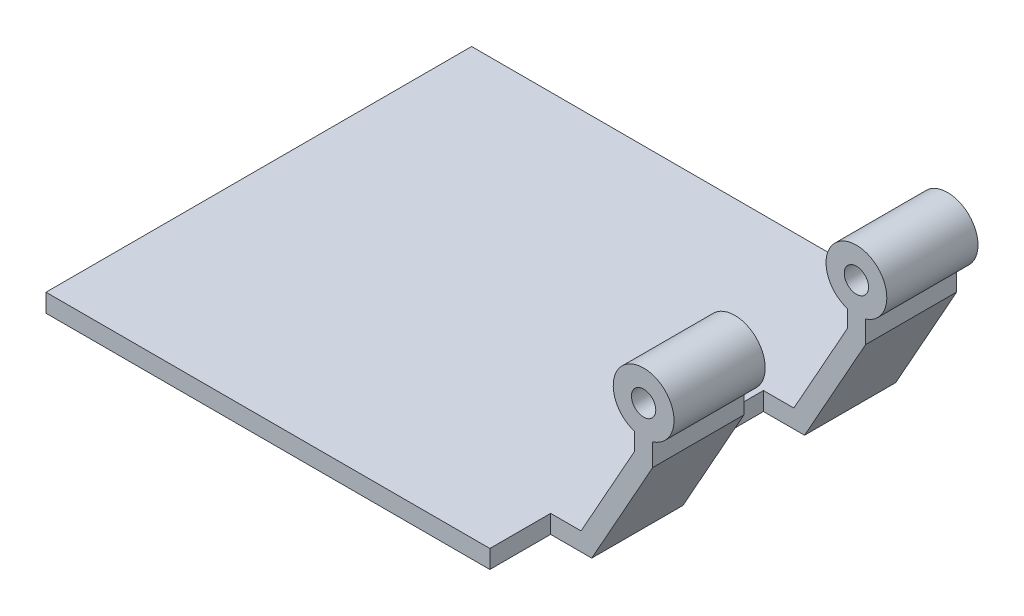
from build123d import *

# Parameters (mm, degrees)
SKETCH1_R               = 5
BOSS_EXTRUDE1_DEPTH     = 50
SKETCH2_R               = 2
CUT_EXTRUDE1_DEPTH      = 51
SKETCH7_W               = 20
SKETCH7_H               = 39.987182744
CUT_EXTRUDE3_DEPTH      = 10
CUT_EXTRUDE3_DEPTH_BACK = 10
BOSS_EXTRUDE2_REACH     = 52
CUT_EXTRUDE4_REACH      = 97.292
SKETCH9_W               = 20
SKETCH9_H               = 10.896319728
CUT_EXTRUDE6_REACH      = 52
SKETCH11_W              = 5
SKETCH11_H              = 3
SKETCH12_W              = 73
SKETCH12_H              = 70
BOSS_EXTRUDE3_DEPTH     = 3
SKETCH13_W              = 6.758772051
SKETCH13_H              = 20
CUT_EXTRUDE7_DEPTH      = 4


with BuildPart() as part:
    # Sketch1 → Boss-Extrude1 (new body)
    with BuildSketch(Plane.XY):
        with Locations((90.291740814, 26.352640412)):
            Circle(SKETCH1_R)
        Polygon((0, 3), (0, 0), (81.758772051, 0), (91.791740814, 17.924366601), (91.791740814, 23.706854983), (88.791740814, 23.706854983), (88.791740814, 18.706854983), (80, 3), align=None)
    extrude(amount=BOSS_EXTRUDE1_DEPTH)

    # Sketch2 → Cut-Extrude1 (cut, through all)
    with BuildSketch(Plane.XY):
        with Locations((90.291740814, 26.352640412)):
            Circle(SKETCH2_R)
    extrude(amount=CUT_EXTRUDE1_DEPTH, mode=Mode.SUBTRACT)

    # Sketch7 → Cut-Extrude3 (cut, two sides)
    with BuildSketch(Plane(origin=(62.254079791, -34.846042362, 0), x_dir=(0, 0, -1), z_dir=(0.872603055, -0.488430045, 0))) as cut_extrude3_sk:
        with Locations((-25, 59.927032101)):
            Rectangle(SKETCH7_W, SKETCH7_H)
    extrude(amount=CUT_EXTRUDE3_DEPTH, mode=Mode.SUBTRACT)
    extrude(cut_extrude3_sk.sketch, amount=-CUT_EXTRUDE3_DEPTH_BACK, mode=Mode.SUBTRACT)

    # Sketch8 → Boss-Extrude2 (add, up to next)
    with BuildSketch(Plane.XY, mode=Mode.PRIVATE) as boss_extrude2_sk1:
        Polygon((66.951015515, 3), (66.951015515, 0), (81.758772051, 0), (79.25400484, 1.667244856), (80, 3), align=None)
    boss_extrude2_tool1 = extrude(boss_extrude2_sk1.sketch, amount=BOSS_EXTRUDE2_REACH, mode=Mode.PRIVATE) - part.part
    add(boss_extrude2_tool1.solids().sort_by_distance((73.552437, 1.463367, 0))[0])

    # Sketch9 → Cut-Extrude4 (cut, up to next)
    with BuildSketch(Plane(origin=(0, 0, 0), x_dir=(0, 0, -1), z_dir=(1, 0, 0)), mode=Mode.PRIVATE) as cut_extrude4_sk1:
        with Locations((-25, 32.01270193)):
            Rectangle(SKETCH9_W, SKETCH9_H)
    cut_extrude4_tool1 = extrude(cut_extrude4_sk1.sketch, amount=CUT_EXTRUDE4_REACH, mode=Mode.PRIVATE) & part.part
    add(cut_extrude4_tool1.solids().sort_by_distance((0, 32.012702, 25))[0], mode=Mode.SUBTRACT)

    # Sketch11 → Cut-Extrude6 (cut, up to next)
    with BuildSketch(Plane.XY.offset(50), mode=Mode.PRIVATE) as cut_extrude6_sk1:
        with Locations((2.5, 1.5)):
            Rectangle(SKETCH11_W, SKETCH11_H)
    cut_extrude6_tool1 = extrude(cut_extrude6_sk1.sketch, amount=-CUT_EXTRUDE6_REACH, mode=Mode.PRIVATE) & part.part
    add(cut_extrude6_tool1.solids().sort_by_distance((2.5, 1.5, 50))[0], mode=Mode.SUBTRACT)

    # Sketch12 → Boss-Extrude3 (add, through all)
    with BuildSketch(Plane(origin=(0, 3, 0), x_dir=(1, 0, 0), z_dir=(0, 1, 0))):
        with Locations((38.5, -25)):
            Rectangle(SKETCH12_W, SKETCH12_H)
    extrude(amount=-BOSS_EXTRUDE3_DEPTH)

    # Sketch13 → Cut-Extrude7 (cut, through all)
    with BuildSketch(Plane(origin=(0, 3, 0), x_dir=(1, 0, 0), z_dir=(0, 1, 0))):
        with Locations((78.379386025, -25)):
            Rectangle(SKETCH13_W, SKETCH13_H)
    extrude(amount=-CUT_EXTRUDE7_DEPTH, mode=Mode.SUBTRACT)


solid = part.part
